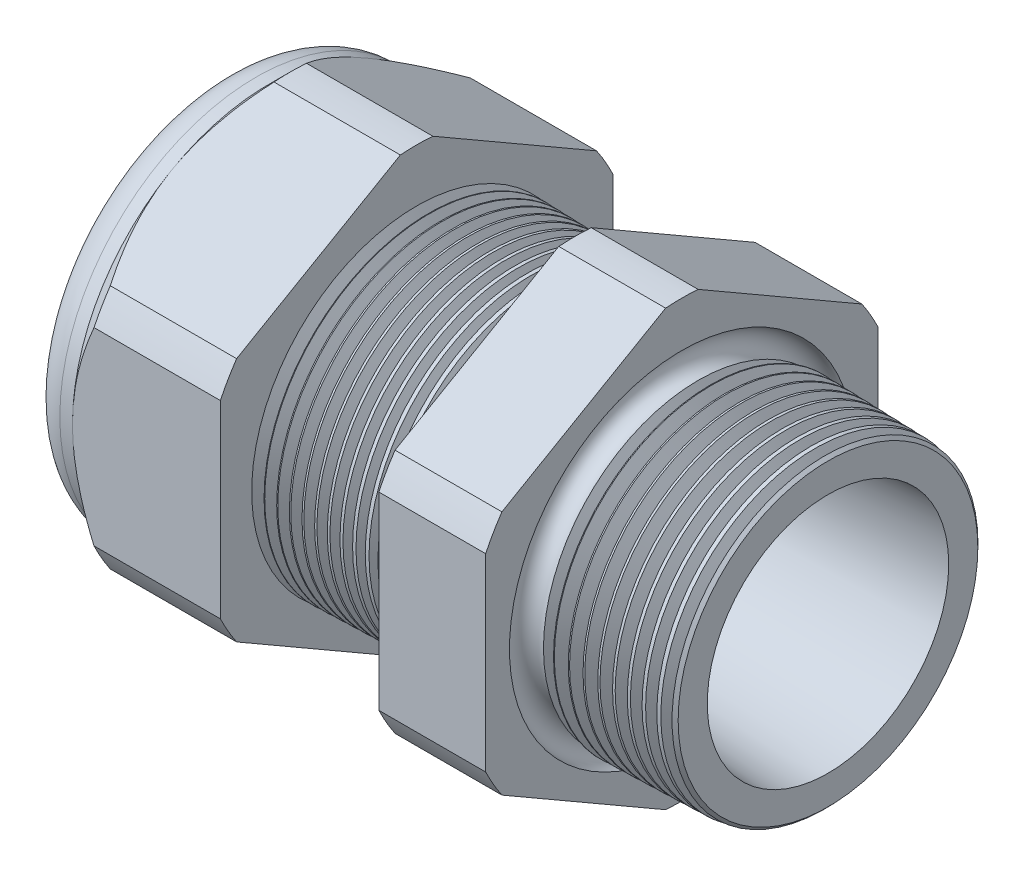
from build123d import *

# Parameters (mm, degrees)
SKETCH12_OUTSIDE_W = 65.136
SKETCH12_OUTSIDE_H = 65.136
CUT_EXTRUDE2_DEPTH = 35.03
FILLET4_R          = 2.032
SKETCH19_OUTSIDE_W = 40.13
SKETCH19_OUTSIDE_H = 42.756
SKETCH19_OUTSIDE_R = 11.938
CUT_EXTRUDE3_DEPTH = 1.999996
CUT_EXTRUDE3_DRAFT = -45
CHAMFER1_SIZE      = 0.260919487
CHAMFER1_SIZE2     = 0.254
SKETCH21_R         = 5.969
PLUG_DEPTH         = 6.35
SKETCH22_R         = 5.715
CUT_EXTRUDE4_DEPTH = 0.508
SKETCH27_R         = 2.032
PLUGHOLES_DEPTH    = 37.322
CIRPATTERN1_COUNT  = 3
LPATTERN1_COUNT    = 13
LPATTERN1_PITCH    = 0.762
LPATTERN2_COUNT    = 10
LPATTERN2_PITCH    = 0.889
SKETCH32_R         = 0.889


with BuildPart() as part:
    # Sketch10 → Revolve2 (revolve)
    with BuildSketch(Plane.XY, mode=Mode.PRIVATE) as revolve2_sk:
        Polygon((-35.814, 5.969), (-24.014, 5.969), (1.016, 7.345566383), (1.016, 9.377566383), (-7.874, 9.610359226), (-7.874, 23.876), (-14.374, 23.876), (-14.374, 9.780567716), (-24.014, 10.033), (-24.014, 23.876), (-33.014, 23.876), (-33.014, 11.938), (-35.814, 11.938), align=None)
    revolve(revolve2_sk.sketch.rotate(Axis((0, 0, 0), (-1, 0, 0)), 90), axis=Axis((0, 0, 0), (-1, 0, 0)))  # turned: the seam where the file's is

    # Sketch12 outside → Cut-Extrude2 (cut, through all)
    with BuildSketch(Plane.ZY.offset(33.014)):
        Rectangle(SKETCH12_OUTSIDE_W, SKETCH12_OUTSIDE_H)
        with BuildLine():
            Line((-0.98819228, 13.214281948), (-10.94980772, 7.462940592))
            ThreePointArc((-10.94980772, 7.462940592), (-11.47585851, 6.62559), (-11.938, 5.751341356))
            Line((-11.938, 5.751341356), (-11.938, -5.751341356))
            ThreePointArc((-11.938, -5.751341356), (-11.47585851, -6.62559), (-10.94980772, -7.462940592))
            Line((-10.94980772, -7.462940592), (-0.98819228, -13.214281948))
            ThreePointArc((-0.98819228, -13.214281948), (0, -13.25118), (0.98819228, -13.214281948))
            Line((0.98819228, -13.214281948), (10.94980772, -7.462940592))
            ThreePointArc((10.94980772, -7.462940592), (11.47585851, -6.62559), (11.938, -5.751341356))
            Line((11.938, -5.751341356), (11.938, 5.751341356))
            ThreePointArc((11.938, 5.751341356), (11.47585851, 6.62559), (10.94980772, 7.462940592))
            Line((10.94980772, 7.462940592), (0.98819228, 13.214281948))
            ThreePointArc((0.98819228, 13.214281948), (0, 13.25118), (-0.98819228, 13.214281948))
        make_face(mode=Mode.SUBTRACT)
    extrude(amount=-CUT_EXTRUDE2_DEPTH, mode=Mode.SUBTRACT)

    # Fillet4
    fillet4_edges = [part.edges().sort_by_distance(p)[0] for p in [
        (-35.814, 0, 11.938),
    ]]
    fillet(fillet4_edges, radius=FILLET4_R)


with BuildPart() as cut_extrude3_tool:
    # Sketch19 outside → Cut-Extrude3 (with draft: the straight prism first)
    with BuildSketch(Plane.ZY.offset(33.014)):
        Rectangle(SKETCH19_OUTSIDE_W, SKETCH19_OUTSIDE_H)
        Circle(SKETCH19_OUTSIDE_R, mode=Mode.SUBTRACT)
    extrude(amount=-CUT_EXTRUDE3_DEPTH)
    # Cut-Extrude3: the draft: its side faces are tilted about the plane it starts from
    cut_extrude3_sides = [cut_extrude3_tool.faces().sort_by_distance(p)[0] for p in [
        (-32.014002, -21.378, 0),
        (-32.014002, 0, 20.065),
        (-32.014002, 21.378, 0),
        (-32.014002, 0, -20.065),
        (-32.014002, 0, -11.938),
    ]]
    draft(cut_extrude3_sides, Plane.ZY.offset(33.014), CUT_EXTRUDE3_DRAFT)


with BuildPart() as part_1:
    add(part.part)

    # Cut-Extrude3: cut by cut_extrude3_tool
    add(cut_extrude3_tool.part, mode=Mode.SUBTRACT)

    # Chamfer1
    chamfer1_edges = [part_1.edges().sort_by_distance(p)[0] for p in [
        (1.016, 0, 9.377566383),
    ]]
    chamfer1_side = [part_1.faces().sort_by_distance(p)[0] for p in [
        (1.016, 0, 7.610804014),
    ]]
    chamfer(chamfer1_edges, length=CHAMFER1_SIZE, length2=CHAMFER1_SIZE2, reference=chamfer1_side[0])

    # Sketch29 → Cut-Revolve1 (revolve, cut)
    with BuildSketch(Plane.XY, mode=Mode.PRIVATE) as cut_revolve1_sk:
        Polygon((-24.014, 10.033), (-23.281016419, 10.013806149), (-23.664130572, 9.388620673), align=None)
    cut_revolve1 = revolve(cut_revolve1_sk.sketch.rotate(Axis((0, 0, 0), (-1, 0, 0)), 90), axis=Axis((0, 0, 0), (-1, 0, 0)), mode=Mode.SUBTRACT)  # turned: the seam where the file's is

    # LPattern1: Cut-Revolve1 ×13
    with Locations(*[(i * LPATTERN1_PITCH, 0, 0) for i in range(1, LPATTERN1_COUNT)]):
        add(cut_revolve1, mode=Mode.SUBTRACT)

    # Sketch30 → Cut-Revolve2 (revolve, cut)
    with BuildSketch(Plane.XY, mode=Mode.PRIVATE) as cut_revolve2_sk:
        Polygon((-7.874, 9.610359226), (-6.994419703, 9.587326605), (-7.454156686, 8.837104034), align=None)
    cut_revolve2 = revolve(cut_revolve2_sk.sketch.rotate(Axis((0, 0, 0), (-1, 0, 0)), 270), axis=Axis((0, 0, 0), (-1, 0, 0)), mode=Mode.SUBTRACT)  # turned: the seam where the file's is

    # LPattern2: Cut-Revolve2 ×10
    with Locations(*[(i * LPATTERN2_PITCH, 0, 0) for i in range(1, LPATTERN2_COUNT)]):
        add(cut_revolve2, mode=Mode.SUBTRACT)

    # Sketch32 → Cut-Revolve3 (revolve, cut)
    with BuildSketch(Plane.XY, mode=Mode.PRIVATE) as cut_revolve3_sk:
        with Locations((-7.747, 9.610359226)):
            Circle(SKETCH32_R)
    revolve(cut_revolve3_sk.sketch.rotate(Axis((0, 0, 0), (-1, 0, 0)), 270), axis=Axis((0, 0, 0), (-1, 0, 0)), mode=Mode.SUBTRACT)  # turned: the seam where the file's is


with BuildPart() as body_2:
    # Sketch21 → plug (new body)
    with BuildSketch(Plane.ZY.offset(35.814)):
        Circle(SKETCH21_R)
    extrude(amount=-PLUG_DEPTH)

    # Sketch22 → Cut-Extrude4 (cut)
    with BuildSketch(Plane.ZY.offset(35.814)):
        Circle(SKETCH22_R)
    extrude(amount=-CUT_EXTRUDE4_DEPTH, mode=Mode.SUBTRACT)

    # Sketch27 → plugholes (cut, through all)
    with BuildSketch(Plane.ZY.offset(35.306)):
        with Locations((-3.674872, 0)):
            Circle(SKETCH27_R)
    plugholes = extrude(amount=-PLUGHOLES_DEPTH, mode=Mode.SUBTRACT)

    # CirPattern1: plugholes ×3 about axis
    cirpattern1_axis = Axis((0, 0, 0), (1, 0, 0))
    for i in range(1, CIRPATTERN1_COUNT):
        add(plugholes.rotate(cirpattern1_axis, i * 360 / CIRPATTERN1_COUNT), mode=Mode.SUBTRACT)


solid = Compound([part_1.part, body_2.part])
